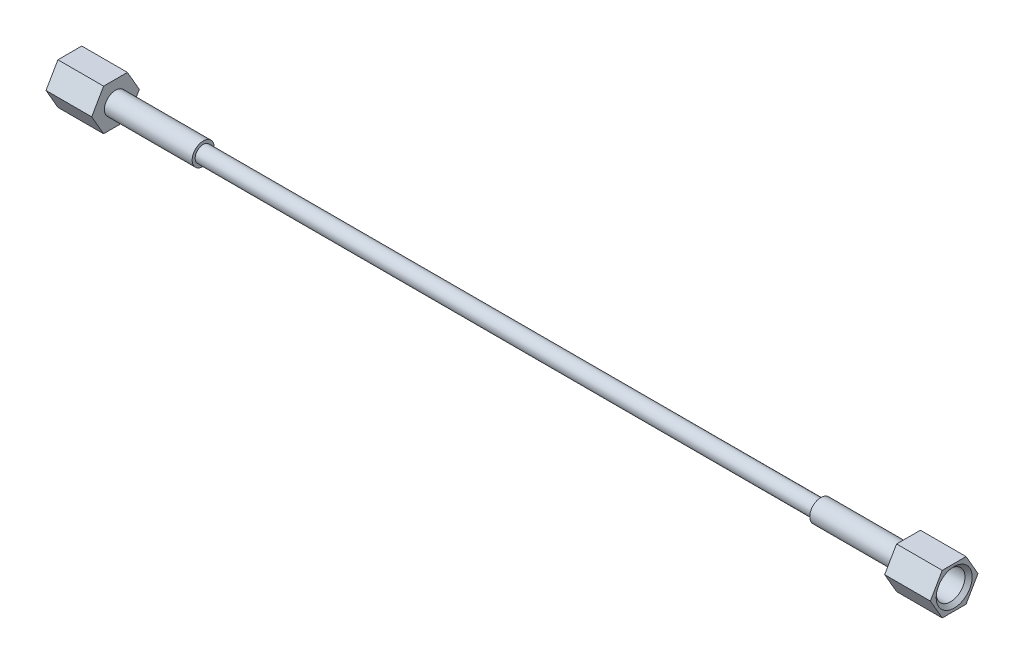
from build123d import *

# Parameters (mm, degrees)
EXTRUDE2_DEPTH = 15.748
CHAMFER2_SIZE  = 1.240155


with BuildPart() as part:
    # Sketch5 → Extrude2 (new body)
    with BuildSketch(Plane(origin=(-6.858, 0, 0), x_dir=(0, 0, -1), z_dir=(1, 0, 0))):
        Polygon((4.106115114, 7.112), (-4.106115114, 7.112), (-8.212230229, 0), (-4.106115114, -7.112), (4.106115114, -7.112), (8.212230229, 0), align=None)
    extrude(amount=EXTRUDE2_DEPTH)

    # Sketch6 → Hole2 (revolve, cut)
    with BuildSketch(Plane(origin=(8.89, 0, 0), x_dir=(0, 0, -1), z_dir=(0, 1, 0))):
        Polygon((0, 0), (0, 15.748), (3.8354, 15.748), (3.8354, 9.566100386), (4.96062, 8.89), (4.96062, 0), align=None)
    revolve(axis=Axis((15.020023899, 0, 0), (-1, 0, 0)), mode=Mode.SUBTRACT)

    # Chamfer2
    chamfer2_edges = [part.edges().sort_by_distance(p)[0] for p in [
        (8.89, 0, 4.96062),
    ]]
    chamfer(chamfer2_edges, length=CHAMFER2_SIZE)


with BuildPart() as body_2:
    # Sketch8 → Revolve2 (revolve)
    with BuildSketch(Plane(origin=(0, 0, 0), x_dir=(-1, 0, 0), z_dir=(0, 0, -1)), mode=Mode.PRIVATE) as revolve2_sk:
        Polygon((0.691362245, 3.81), (2.385428675, 0.9906), (284.634571325, 0.9906), (286.328637755, 3.81), (249.936, 3.81), (249.936, 2.7686), (37.084, 2.7686), (37.084, 3.81), align=None)
    revolve(revolve2_sk.sketch.rotate(Axis((-0.691362245, 0, 0), (-1, 0, 0)), 270), axis=Axis((-0.691362245, 0, 0), (-1, 0, 0)))  # turned: the seam where the file's is


with BuildPart() as body_3:
    # Mirror2: mirrored copy
    add(part.part.mirror(Plane(origin=(-143.51, 0, 0), x_dir=(0, 0, 1), z_dir=(1, 0, 0))))


solid = Compound([part.part, body_2.part, body_3.part])
